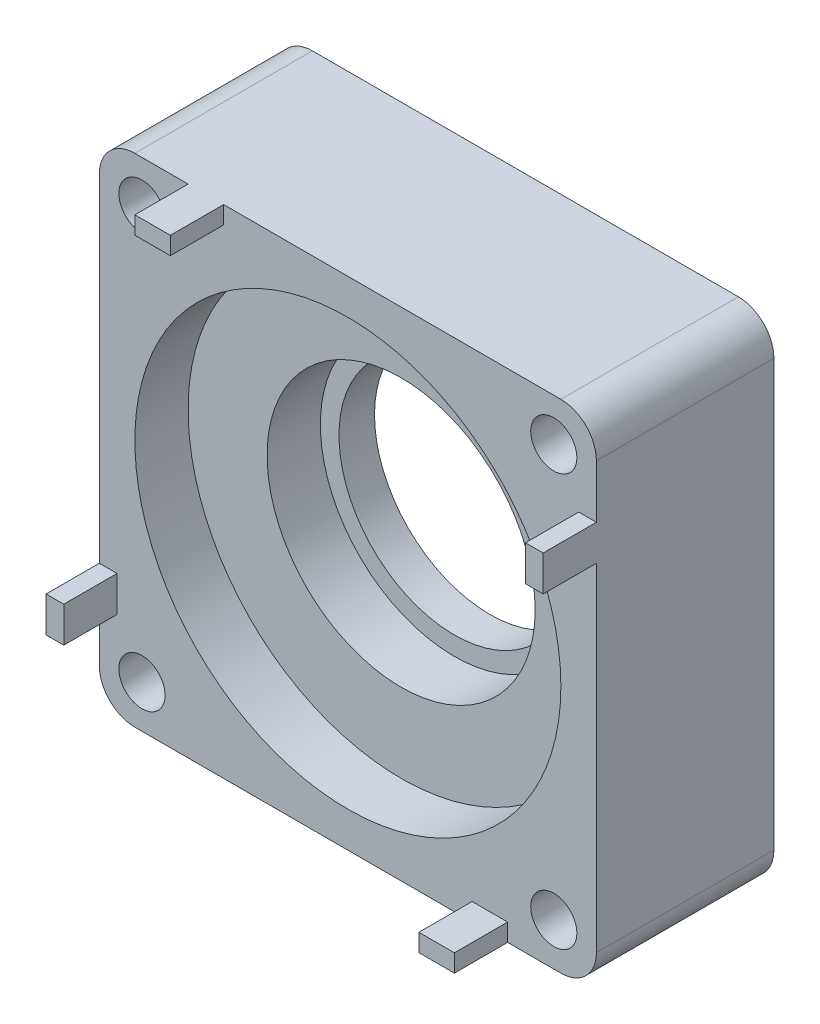
from build123d import *

# Parameters (mm, degrees)
SKETCH_1_W               = 28
SKETCH_1_H               = 28
EXTRUDE_1_DEPTH          = 10
SKETCH_2_R               = 6.5
CUT_EXTRUDE_1_DEPTH      = 11
SKETCH_3_R               = 7.55
CUT_EXTRUDE_2_DEPTH      = 6
SKETCH_6_R               = 11.05
CUT_EXTRUDE_3_DEPTH      = 2
FILLET_1_R               = 2
SKETCH_7_W               = 0.995329216
SKETCH_7_H               = 2
EXTRUDE_2_DEPTH          = 3
PATTERN_CIRCULAR_1_COUNT = 4
SKETCH_8_R               = 12
CUT_EXTRUDE_4_DEPTH      = 3
SKETCH_9_R               = 1.3
CUT_EXTRUDE_5_DEPTH      = 14


with BuildPart() as part:
    # 草图1 → 凸台-拉伸1 (new body)
    with BuildSketch(Plane.XY):
        Rectangle(SKETCH_1_W, SKETCH_1_H)
    extrude(amount=EXTRUDE_1_DEPTH)

    # 草图2 → 切除-拉伸1 (cut, through all)
    with BuildSketch(Plane.XY.offset(10)):
        Circle(SKETCH_2_R)
    extrude(amount=-CUT_EXTRUDE_1_DEPTH, mode=Mode.SUBTRACT)

    # 草图3 → 切除-拉伸2 (cut)
    with BuildSketch(Plane.XY.offset(10)):
        Circle(SKETCH_3_R)
    extrude(amount=-CUT_EXTRUDE_2_DEPTH, mode=Mode.SUBTRACT)

    # 草图6 → 切除-拉伸3 (cut)
    with BuildSketch(Plane(origin=(0, 0, 0), x_dir=(-1, 0, 0), z_dir=(0, 0, -1))):
        Circle(SKETCH_6_R)
    extrude(amount=-CUT_EXTRUDE_3_DEPTH, mode=Mode.SUBTRACT)

    # 圆角1
    fillet_1_edges = [part.edges().sort_by_distance(p)[0] for p in [
        (14, -14, 5),
        (-14, -14, 5),
        (-14, 14, 5),
        (14, 14, 5),
    ]]
    fillet(fillet_1_edges, radius=FILLET_1_R)

    # 草图7 → 凸台-拉伸2 (add)
    with BuildSketch(Plane.XY.offset(10)):
        with Locations((-13.502335392, -8)):
            Rectangle(SKETCH_7_W, SKETCH_7_H)
    extrude_2 = extrude(amount=EXTRUDE_2_DEPTH)

    # 阵列(圆周)1: 凸台-拉伸2 ×4 about axis
    pattern_circular_1_axis = Axis((0, 0, 0), (0, 0, 1))
    for i in range(1, PATTERN_CIRCULAR_1_COUNT):
        add(extrude_2.rotate(pattern_circular_1_axis, i * 360 / PATTERN_CIRCULAR_1_COUNT))

    # 草图8 → 切除-拉伸4 (cut)
    with BuildSketch(Plane.XY.offset(10)):
        Circle(SKETCH_8_R)
    extrude(amount=-CUT_EXTRUDE_4_DEPTH, mode=Mode.SUBTRACT)

    # 草图9 → 切除-拉伸5 (cut, through all)
    with BuildSketch(Plane(origin=(0, 0, 0), x_dir=(-1, 0, 0), z_dir=(0, 0, -1))):
        with Locations((-11.6, 11.6)):
            Circle(SKETCH_9_R)
        with Locations((11.6, 11.6)):
            Circle(SKETCH_9_R)
        with Locations((11.6, -11.6)):
            Circle(SKETCH_9_R)
        with Locations((-11.6, -11.6)):
            Circle(SKETCH_9_R)
    extrude(amount=-CUT_EXTRUDE_5_DEPTH, mode=Mode.SUBTRACT)


solid = part.part
